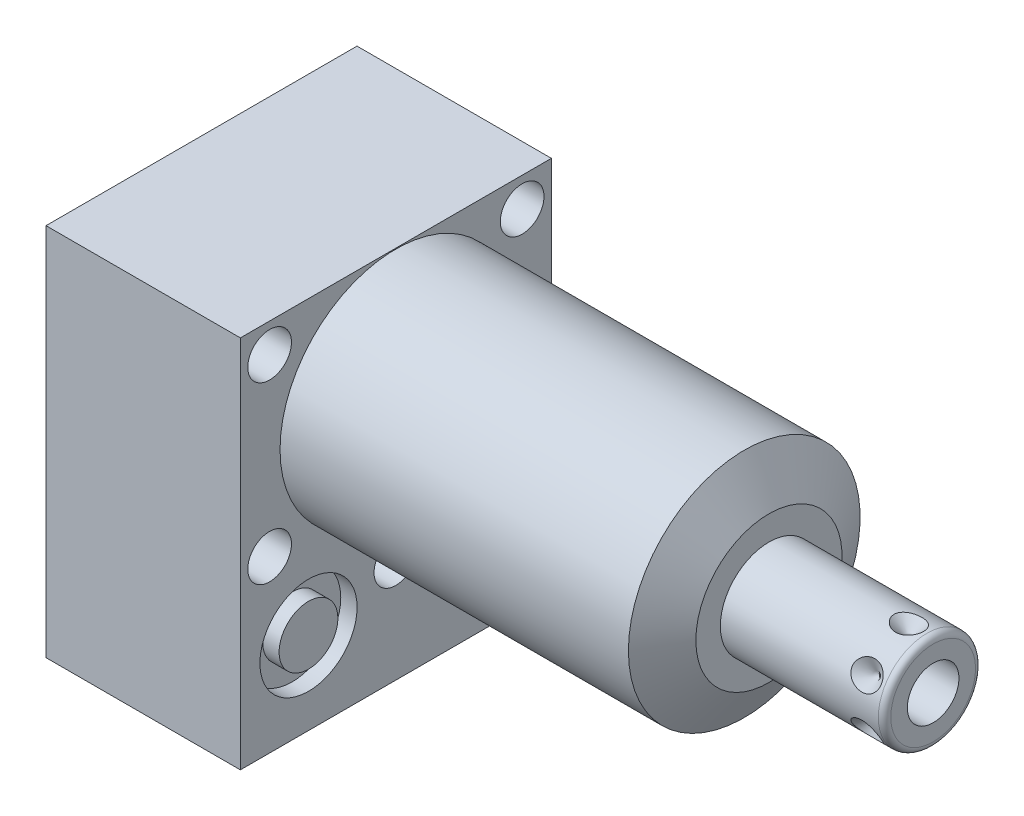
from build123d import *

# Parameters (mm, degrees)
SKETCH1_W           = 50.8
SKETCH1_H           = 61.1124
EXTRUDE1_DEPTH      = 60.9346
EXTRUDE1_DEPTH_BACK = 31.75
CUT_EXTRUDE1_REACH  = 62.935
SKETCH2_W           = 50.8
SKETCH2_H           = 61.1124
SKETCH2_R           = 18.923
SKETCH18_R          = 7.9375
CUT_EXTRUDE2_DEPTH  = 2.667
SKETCH19_R          = 7.9375
CUT_EXTRUDE3_DEPTH  = 2.667
SKETCH20_R          = 9.525
CUT_EXTRUDE4_DEPTH  = 0.254
SKETCH12_R          = 6.4389
EXTRUDE2_DEPTH      = 1.651
EXTRUDE3_START      = -2.667
SKETCH13_R          = 4.8006
EXTRUDE3_DEPTH      = 2.667
SKETCH14_R          = 1.7653
SKETCH15_R          = 1.7653
CIRPATTERN1_COUNT   = 6
SKETCH21_W          = 3.5687
SKETCH21_H          = 31.75
HOLE1_AT_2_COUNT    = 2
HOLE1_AT_2_PITCH    = 44.445239059
HOLE1_AT_3_COUNT    = 2
HOLE1_AT_3_PITCH    = 28.5496
HOLE1_AT_4_COUNT    = 2
HOLE1_AT_4_PITCH    = 41.2496
HOLE1_AT_5_COUNT    = 2
HOLE1_AT_5_PITCH    = 50.165816652
SKETCH24_R          = 4.8006
EXTRUDE4_DEPTH      = 2.667


with BuildPart() as part:
    # Sketch1 → Extrude1 (new body, two sides)
    with BuildSketch(Plane(origin=(0, 0, 0), x_dir=(0, 0, -1), z_dir=(1, 0, 0))) as extrude1_sk:
        with Locations((0, -11.5062)):
            Rectangle(SKETCH1_W, SKETCH1_H)
    extrude(amount=EXTRUDE1_DEPTH)
    extrude(extrude1_sk.sketch, amount=-EXTRUDE1_DEPTH_BACK)

    # Sketch2 → Cut-Extrude1 (cut, up to next)
    with BuildSketch(Plane(origin=(0, 0, 0), x_dir=(0, 0, -1), z_dir=(1, 0, 0)), mode=Mode.PRIVATE) as cut_extrude1_sk1:
        with Locations((0, -11.5062)):
            Rectangle(SKETCH2_W, SKETCH2_H)
        Circle(SKETCH2_R, mode=Mode.SUBTRACT)
    cut_extrude1_tool1 = extrude(cut_extrude1_sk1.sketch, amount=CUT_EXTRUDE1_REACH, mode=Mode.PRIVATE) & part.part
    add(cut_extrude1_tool1.solids().sort_by_distance((0, 18.970531, 0))[0], mode=Mode.SUBTRACT)

    # Sketch3 → Cut-Revolve1 (revolve, cut)
    with BuildSketch(Plane.XY, mode=Mode.PRIVATE) as cut_revolve1_sk:
        Polygon((56.90180837, 18.923), (60.9346, 11.938), (60.9346, 18.923), align=None)
    revolve(cut_revolve1_sk.sketch.rotate(Axis((56.700168788, 0, 0), (1, 0, 0)), 90), axis=Axis((56.700168788, 0, 0), (1, 0, 0)), mode=Mode.SUBTRACT)  # turned: the seam where the file's is

    # S2D0002 → Cut-Revolve2 (revolve, cut)
    with BuildSketch(Plane(origin=(-29.083, -28.575, 14.2748), x_dir=(0, 1, 0), z_dir=(0, 0, 1)), mode=Mode.PRIVATE) as cut_revolve2_sk:
        Polygon((0, 0), (4.5466, 0), (4.106586662, -2.0701), (3.4544, -2.722286662), (3.4544, -13.97), (0, -13.97), align=None)
    revolve(cut_revolve2_sk.sketch.rotate(Axis((-14.4145, -28.575, 14.2748), (-1, 0, 0)), 90), axis=Axis((-14.4145, -28.575, 14.2748), (-1, 0, 0)), mode=Mode.SUBTRACT)  # turned: the seam where the file's is

    # Sketch5 → Cut-Revolve3 (revolve, cut)
    with BuildSketch(Plane(origin=(-29.083, -28.575, -14.2748), x_dir=(0, 1, 0), z_dir=(0, 0, 1)), mode=Mode.PRIVATE) as cut_revolve3_sk:
        Polygon((0, 0), (4.5466, 0), (4.106586662, -2.0701), (3.4544, -2.722286662), (3.4544, -13.97), (0, -13.97), align=None)
    revolve(cut_revolve3_sk.sketch.rotate(Axis((-14.4145, -28.575, -14.2748), (-1, 0, 0)), 90), axis=Axis((-14.4145, -28.575, -14.2748), (-1, 0, 0)), mode=Mode.SUBTRACT)  # turned: the seam where the file's is

    # Sketch6 → Cut-Revolve4 (revolve, cut)
    with BuildSketch(Plane(origin=(-2.667, -28.575, 14.2748), x_dir=(0, -1, 0), z_dir=(0, 0, 1)), mode=Mode.PRIVATE) as cut_revolve4_sk:
        Polygon((0, 0), (4.5466, 0), (4.106586662, -2.0701), (3.4544, -2.722286662), (3.4544, -12.192), (0, -12.192), align=None)
    revolve(cut_revolve4_sk.sketch.rotate(Axis((-15.4686, -28.575, 14.2748), (1, 0, 0)), 90), axis=Axis((-15.4686, -28.575, 14.2748), (1, 0, 0)), mode=Mode.SUBTRACT)  # turned: the seam where the file's is

    # Sketch7 → Cut-Revolve5 (revolve, cut)
    with BuildSketch(Plane(origin=(-2.667, -28.575, -14.2748), x_dir=(0, -1, 0), z_dir=(0, 0, 1)), mode=Mode.PRIVATE) as cut_revolve5_sk:
        Polygon((0, 0), (4.5466, 0), (4.106586662, -2.0701), (3.4544, -2.722286662), (3.4544, -12.192), (0, -12.192), align=None)
    revolve(cut_revolve5_sk.sketch.rotate(Axis((-15.4686, -28.575, -14.2748), (1, 0, 0)), 90), axis=Axis((-15.4686, -28.575, -14.2748), (1, 0, 0)), mode=Mode.SUBTRACT)  # turned: the seam where the file's is

    # Sketch18 → Cut-Extrude2 (cut)
    with BuildSketch(Plane.ZY.offset(31.75)):
        with Locations((-14.2748, -28.575)):
            Circle(SKETCH18_R)
        with Locations((14.2748, -28.575)):
            Circle(SKETCH18_R)
    extrude(amount=-CUT_EXTRUDE2_DEPTH, mode=Mode.SUBTRACT)

    # Sketch19 → Cut-Extrude3 (cut)
    with BuildSketch(Plane(origin=(0, 0, 0), x_dir=(0, 0, -1), z_dir=(1, 0, 0))):
        with Locations((-14.2748, -28.575)):
            Circle(SKETCH19_R)
        with Locations((14.2748, -28.575)):
            Circle(SKETCH19_R)
    extrude(amount=-CUT_EXTRUDE3_DEPTH, mode=Mode.SUBTRACT)

    # Sketch8 → Cut-Revolve6 (revolve, cut)
    with BuildSketch(Plane(origin=(-15.875, -43.688, 14.2748), x_dir=(-1, 0, 0), z_dir=(0, 0, 1)), mode=Mode.PRIVATE) as cut_revolve6_sk:
        Polygon((0, -1.8796), (6.1849, -1.8796), (5.642306865, -4.4323), (4.9784, -5.096206865), (4.9784, -20.9296), (0, -20.9296), align=None)
    revolve(cut_revolve6_sk.sketch.rotate(Axis((-15.875, -17.018, 14.2748), (0, -1, 0)), 270), axis=Axis((-15.875, -17.018, 14.2748), (0, -1, 0)), mode=Mode.SUBTRACT)  # turned: the seam where the file's is

    # Sketch9 → Cut-Revolve7 (revolve, cut)
    with BuildSketch(Plane(origin=(-15.875, -43.688, -14.2748), x_dir=(-1, 0, 0), z_dir=(0, 0, 1)), mode=Mode.PRIVATE) as cut_revolve7_sk:
        Polygon((0, -1.8796), (6.1849, -1.8796), (5.642306865, -4.4323), (4.9784, -5.096206865), (4.9784, -20.9296), (0, -20.9296), align=None)
    revolve(cut_revolve7_sk.sketch.rotate(Axis((-15.875, -17.018, -14.2748), (0, -1, 0)), 270), axis=Axis((-15.875, -17.018, -14.2748), (0, -1, 0)), mode=Mode.SUBTRACT)  # turned: the seam where the file's is

    # Sketch20 → Cut-Extrude4 (cut)
    with BuildSketch(Plane.XZ.offset(42.0624)):
        with Locations(Location((-15.875, 14.2748, 0), (0, 0, 270))):  # turned: the seam where the file's is
            Circle(SKETCH20_R)
        with Locations(Location((-15.875, -14.2748, 0), (0, 0, 270))):  # turned: the seam where the file's is
            Circle(SKETCH20_R)
    extrude(amount=-CUT_EXTRUDE4_DEPTH, mode=Mode.SUBTRACT)

    # Sketch10 → Revolve1 (revolve)
    with BuildSketch(Plane.XY, mode=Mode.PRIVATE) as revolve1_sk:
        with BuildLine():
            Line((60.9346, 0), (60.9346, 7.9375))
            Line((60.9346, 7.9375), (86.741, 7.9375))
            ThreePointArc((86.741, 7.9375), (87.45942049, 7.63992049), (87.757, 6.9215))
            Line((87.757, 6.9215), (87.757, 0))
            Line((87.757, 0), (60.9346, 0))
        make_face()
    revolve(revolve1_sk.sketch.rotate(Axis((59.59348, 0, 0), (1, 0, 0)), 90), axis=Axis((59.59348, 0, 0), (1, 0, 0)))  # turned: the seam where the file's is

    # S2D0001 → Cut-Revolve8 (revolve, cut)
    with BuildSketch(Plane(origin=(87.757, -4.2164, 0), x_dir=(0, -1, 0), z_dir=(0, 0, 1)), mode=Mode.PRIVATE) as cut_revolve8_sk:
        Polygon((0, 0), (0, -15.24), (-4.2164, -17.773468714), (-4.2164, 0), align=None)
    revolve(cut_revolve8_sk.sketch.rotate(Axis((62.891960697, 0, 0), (1, 0, 0)), 270), axis=Axis((62.891960697, 0, 0), (1, 0, 0)), mode=Mode.SUBTRACT)  # turned: the seam where the file's is

    # Sketch12 → Extrude2 (add)
    with BuildSketch(Plane(origin=(-31.75, -41.8084, 0), x_dir=(0, 0, -1), z_dir=(0, -1, 0))):
        with Locations((-14.2748, 15.875)):
            Circle(SKETCH12_R)
    extrude(amount=EXTRUDE2_DEPTH)

    # Sketch13 → Extrude3 (add)
    with BuildSketch(Plane(origin=(0, 0, 0), x_dir=(0, 0, -1), z_dir=(1, 0, 0)).offset(EXTRUDE3_START)):
        with Locations((-14.2748, -28.575)):
            Circle(SKETCH13_R)
    extrude(amount=EXTRUDE3_DEPTH)

    # Sketch16 → Cut-Revolve9 (revolve, cut)
    with BuildSketch(Plane(origin=(83.7946, -7.9375, 0), x_dir=(-1, 0, 0), z_dir=(0, 0, 1)), mode=Mode.PRIVATE) as cut_revolve9_sk:
        Polygon((0, 0), (2.413, 0), (0, -2.413), align=None)
    cut_revolve9 = revolve(cut_revolve9_sk.sketch.rotate(Axis((83.7946, -4.132061843, 0), (0, -1, 0)), 90), axis=Axis((83.7946, -4.132061843, 0), (0, -1, 0)), mode=Mode.SUBTRACT)  # turned: the seam where the file's is

    # CirPattern1: Cut-Revolve9 ×6 about axis
    cirpattern1_axis = Axis((60.9356, 0, 0), (-1, 0, 0))
    for i in range(1, CIRPATTERN1_COUNT):
        add(cut_revolve9.rotate(cirpattern1_axis, i * 360 / CIRPATTERN1_COUNT), mode=Mode.SUBTRACT)

    # Sketch21 → Hole1 (revolve, cut)
    with BuildSketch(Plane(origin=(0, 14.2748, 20.6248), x_dir=(0, 0, -1), z_dir=(0, 1, 0))):
        with Locations((1.78435, 15.875)):
            Rectangle(SKETCH21_W, SKETCH21_H)
    hole1 = revolve(axis=Axis((-110, 14.2748, 20.6248), (1, 0, 0)), mode=Mode.SUBTRACT)

    # Hole1 at 2: Hole1 ×2
    with Locations(*[Vector(0, -0.885809163, -0.464049703) * (i * HOLE1_AT_2_PITCH) for i in range(1, HOLE1_AT_2_COUNT)]):
        add(hole1, mode=Mode.SUBTRACT)

    # Hole1 at 3: Hole1 ×2
    with Locations(*[(0, -i * HOLE1_AT_3_PITCH, 0) for i in range(1, HOLE1_AT_3_COUNT)]):
        add(hole1, mode=Mode.SUBTRACT)

    # Hole1 at 4: Hole1 ×2
    with Locations(*[(0, 0, -i * HOLE1_AT_4_PITCH) for i in range(1, HOLE1_AT_4_COUNT)]):
        add(hole1, mode=Mode.SUBTRACT)

    # Hole1 at 5: Hole1 ×2
    with Locations(*[Vector(0, -0.569104659, -0.822265095) * (i * HOLE1_AT_5_PITCH) for i in range(1, HOLE1_AT_5_COUNT)]):
        add(hole1, mode=Mode.SUBTRACT)

    # Sketch24 → Extrude4 (add)
    with BuildSketch(Plane.ZY.offset(29.083)):
        with Locations(Location((14.2748, -28.575, 0), (0, 0, 180))):  # turned: the seam where the file's is
            Circle(SKETCH24_R)
    extrude(amount=EXTRUDE4_DEPTH)


with BuildPart() as body_2:
    # Sketch14 → Revolve2 (revolve)
    with BuildSketch(Plane(origin=(0, -28.575, -14.2748), x_dir=(0, 0, -1), z_dir=(0, -1, 0)), mode=Mode.PRIVATE) as revolve2_sk:
        with Locations((6.1722, -0.9017)):
            Circle(SKETCH14_R)
    revolve(revolve2_sk.sketch.rotate(Axis((-2.84353, -28.575, -14.2748), (1, 0, 0)), 180), axis=Axis((-2.84353, -28.575, -14.2748), (1, 0, 0)))  # turned: the seam where the file's is


with BuildPart() as body_3:
    # Sketch15 → Revolve3 (revolve)
    with BuildSketch(Plane(origin=(0, -28.575, -14.2748), x_dir=(0, 0, -1), z_dir=(0, -1, 0)), mode=Mode.PRIVATE) as revolve3_sk:
        with Locations((6.1722, -30.8483)):
            Circle(SKETCH15_R)
    revolve(revolve3_sk.sketch.rotate(Axis((-32.79013, -28.575, -14.2748), (1, 0, 0)), 180), axis=Axis((-32.79013, -28.575, -14.2748), (1, 0, 0)))  # turned: the seam where the file's is


solid = Compound([part.part, body_2.part, body_3.part])
